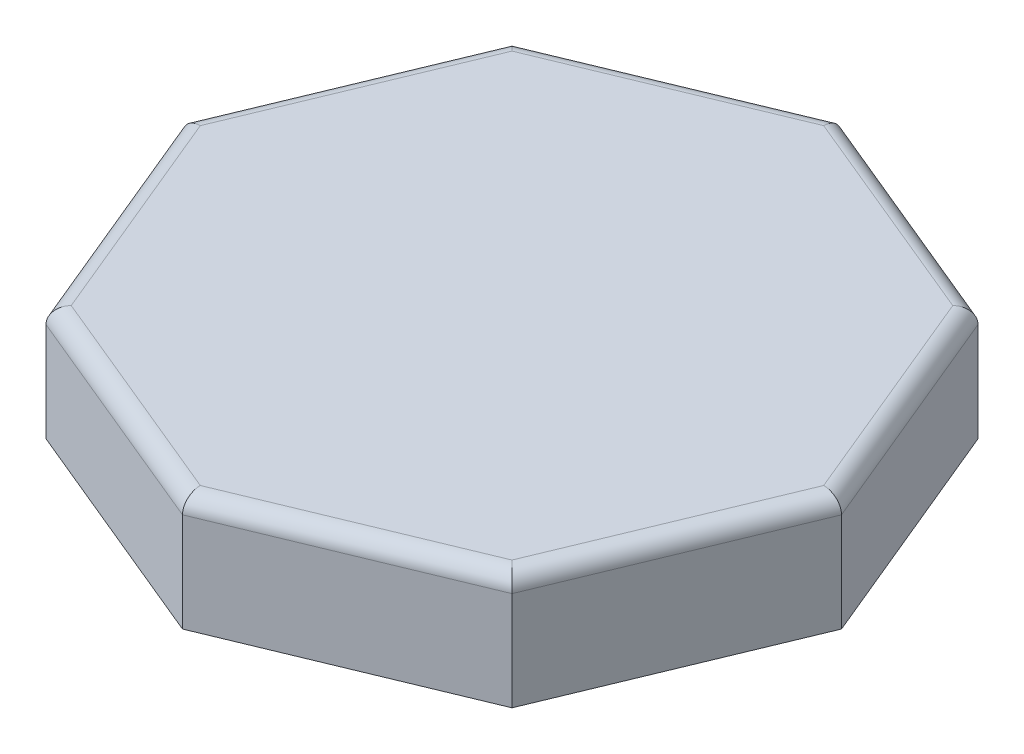
from build123d import *

# Parameters (mm, degrees)
BOSS_EXTRUDE1_DEPTH = 70
SHELL1_T            = -3
SKETCH5_W           = 100
SKETCH5_H           = 80
CUT_EXTRUDE2_DEPTH  = 30
FILLET1_R           = 10
FILLET2_R           = 3


with BuildPart() as part:
    # Sketch3 → Boss-Extrude1 (new body)
    with BuildSketch(Plane(origin=(0, 0, 0), x_dir=(1, 0, 0), z_dir=(0, 1, 0))):
        Polygon((0, 199.904133626), (-141.353568474, 141.353568474), (-199.904133626, 0), (-141.353568474, -141.353568474), (0, -199.904133626), (141.353568474, -141.353568474), (199.904133626, 0), (141.353568474, 141.353568474), align=None)
    extrude(amount=BOSS_EXTRUDE1_DEPTH)

    # Shell1
    shell1_openings = [part.faces().sort_by_distance(p)[0] for p in [
        (0, 0, 0),
    ]]
    offset(amount=SHELL1_T, openings=shell1_openings, kind=Kind.INTERSECTION)

    # Sketch5 → Cut-Extrude2 (cut)
    with BuildSketch(Plane(origin=(331, 0, 0), x_dir=(0, 0, -1), z_dir=(1, 0, 0))):
        with Locations((0, 40)):
            Rectangle(SKETCH5_W, SKETCH5_H)
    extrude(amount=-CUT_EXTRUDE2_DEPTH, mode=Mode.SUBTRACT)

    # Fillet1
    fillet1_edges = [part.edges().sort_by_distance(p)[0] for p in [
        (170.62885105, 70, -70.676784237),
        (70.676784237, 70, -170.62885105),
        (-70.676784237, 70, -170.62885105),
        (-170.62885105, 70, -70.676784237),
        (-170.62885105, 70, 70.676784237),
        (-70.676784237, 70, 170.62885105),
        (70.676784237, 70, 170.62885105),
        (170.62885105, 70, 70.676784237),
    ]]
    fillet(fillet1_edges, radius=FILLET1_R)

    # Fillet2
    fillet2_edges = [part.edges().sort_by_distance(p)[0] for p in [
        (69.52873394, 67, 167.857212453),
        (167.857212453, 67, 69.52873394),
        (167.857212453, 67, -69.52873394),
        (69.52873394, 67, -167.857212453),
        (-69.52873394, 67, -167.857212453),
        (-167.857212453, 67, -69.52873394),
        (-167.857212453, 67, 69.52873394),
        (-69.52873394, 67, 167.857212453),
    ]]
    fillet(fillet2_edges, radius=FILLET2_R)


solid = part.part
